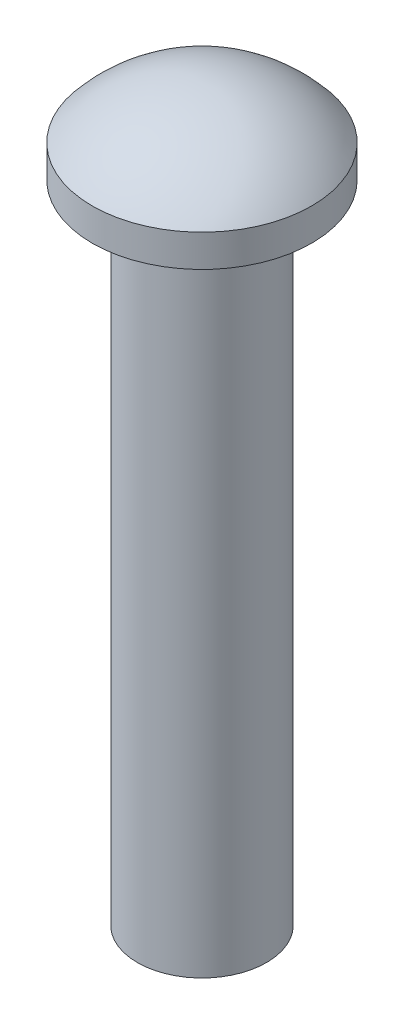
from build123d import *


with BuildPart() as part:
    # Sketch1 → Revolve1 (revolve)
    with BuildSketch(Plane.XY):
        with BuildLine():
            Line((-1, 0), (-1.7, 0))
            Line((-1.7, 0), (-1.7, 0.5))
            ThreePointArc((-1.7, 0.5), (-0.939414711, 1.090006262), (0, 1.3))
            Line((0, 1.3), (0, 0))
            Line((0, 0), (0, -10))
            Line((0, -10), (-1, -10))
            Line((-1, -10), (-1, 0))
        make_face()
    revolve(axis=Axis((0, 0, 0), (0, -1, 0)))


solid = part.part
